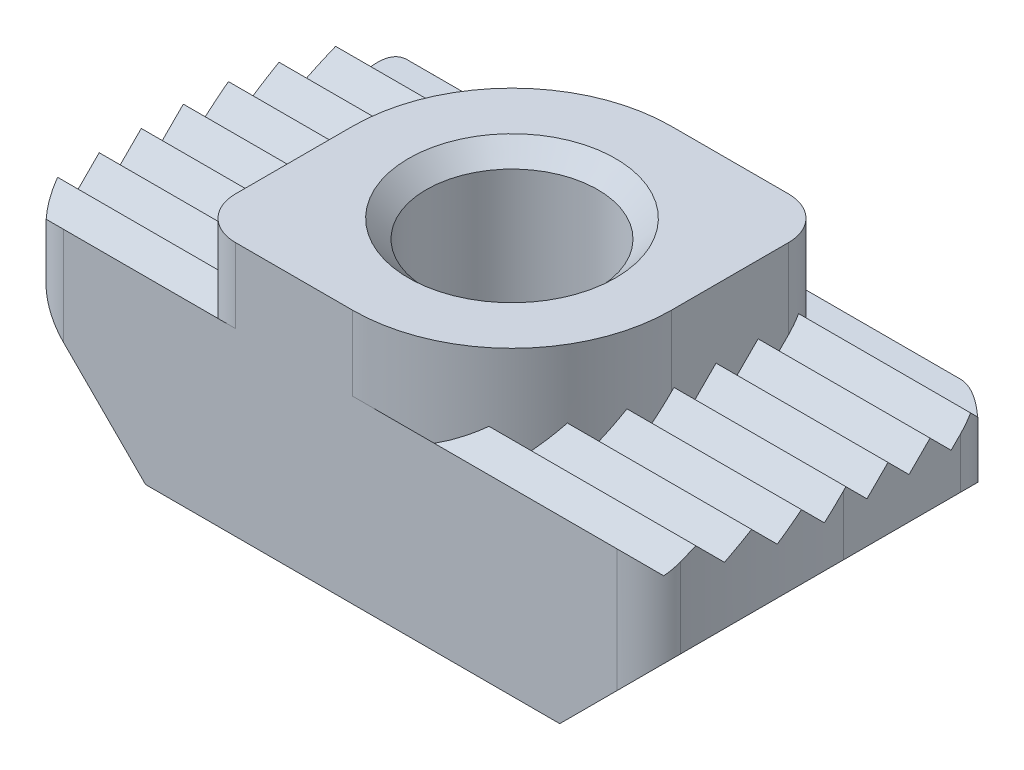
from build123d import *

# Parameters (mm, degrees)
BOSS_EXTRUDE1_DEPTH = 8.001
CUT_EXTRUDE1_DEPTH  = 7.6962
CUT_EXTRUDE2_DEPTH  = 7.6962
SKETCH8_W           = 32.004
SKETCH8_H           = 15.3924
CUT_EXTRUDE3_DEPTH  = 7.6962
BOSS_EXTRUDE2_DEPTH = 3.0734


with BuildPart() as part:
    # Sketch1 → Boss-Extrude1 (new body, symmetric)
    with BuildSketch(Plane(origin=(0, 0, 0), x_dir=(0, 0, -1), z_dir=(1, 0, 0))):
        Polygon((-3.8481, 4.34848), (-3.8481, 0), (3.8481, 0), (3.8481, 4.34848), (3.6195, 3.99288), (3.1115, 4.50088), (2.6035, 3.99288), (2.0955, 4.50088), (1.5875, 3.99288), (1.0795, 4.50088), (0.5715, 3.99288), (0.0635, 4.50088), (-0.4445, 3.99288), (-0.9525, 4.50088), (-1.4605, 3.99288), (-1.9685, 4.50088), (-2.4765, 3.99288), (-2.9845, 4.50088), (-3.4925, 3.99288), align=None)
    extrude(amount=BOSS_EXTRUDE1_DEPTH, both=True)

    # Sketch2 → Cut-Extrude1 (cut, symmetric)
    with BuildSketch(Plane.XY):
        Polygon((-10.541, 2.99974), (-10.541, -2.99974), (0, -2.99974), (0, 0), (-5.00126, 0), (-8.001, 2.99974), align=None)
    extrude(amount=CUT_EXTRUDE1_DEPTH, both=True, mode=Mode.SUBTRACT)

    # Sketch5 → Cut-Extrude2 (cut, symmetric)
    with BuildSketch(Plane.XY):
        Polygon((0, 0), (0, -2.99974), (10.541, -2.99974), (10.541, 2.99974), (8.001, 2.99974), (5.00126, 0), align=None)
    extrude(amount=CUT_EXTRUDE2_DEPTH, both=True, mode=Mode.SUBTRACT)

    # Sketch8 → Cut-Extrude3 (cut)
    with BuildSketch(Plane(origin=(0, 0, 0), x_dir=(1, 0, 0), z_dir=(0, 1, 0))):
        Rectangle(SKETCH8_W, SKETCH8_H)
        with BuildLine():
            Line((-6.985, -3.8481), (6.385094721, -3.8481))
            ThreePointArc((6.385094721, -3.8481), (6.939045596, -3.683800903), (7.313835784, -3.244041788))
            ThreePointArc((7.313835784, -3.244041788), (7.827323972, -1.658010991), (8.001, 0))
            Line((8.001, 0), (8.001, 2.8321))
            ThreePointArc((8.001, 2.8321), (7.70342049, 3.55052049), (6.985, 3.8481))
            Line((6.985, 3.8481), (-6.385094721, 3.8481))
            ThreePointArc((-6.385094721, 3.8481), (-6.939045596, 3.683800903), (-7.313835784, 3.244041788))
            ThreePointArc((-7.313835784, 3.244041788), (-7.827323972, 1.658010991), (-8.001, 0))
            Line((-8.001, 0), (-8.001, -2.8321))
            ThreePointArc((-8.001, -2.8321), (-7.70342049, -3.55052049), (-6.985, -3.8481))
        make_face(mode=Mode.SUBTRACT)
    extrude(amount=CUT_EXTRUDE3_DEPTH, mode=Mode.SUBTRACT)

    # Sketch9 → Boss-Extrude2 (add)
    with BuildSketch(Plane(origin=(0, 6.1468, 0), x_dir=(1, 0, 0), z_dir=(0, 1, 0))):
        with BuildLine():
            Line((-2.8321, -3.8481), (0, -3.8481))
            ThreePointArc((0, -3.8481), (2.721017605, -2.721017605), (3.8481, 0))
            Line((3.8481, 0), (3.8481, 2.8321))
            ThreePointArc((3.8481, 2.8321), (3.55052049, 3.55052049), (2.8321, 3.8481))
            Line((2.8321, 3.8481), (0, 3.8481))
            ThreePointArc((0, 3.8481), (-2.721017605, 2.721017605), (-3.8481, 0))
            Line((-3.8481, 0), (-3.8481, -2.8321))
            ThreePointArc((-3.8481, -2.8321), (-3.55052049, -3.55052049), (-2.8321, -3.8481))
        make_face()
    extrude(amount=-BOSS_EXTRUDE2_DEPTH)

    # Sketch10 → Cut-Revolve1 (revolve, cut)
    with BuildSketch(Plane(origin=(0, 6.1468, 0), x_dir=(-1, 0, 0), z_dir=(0, 0, 1))):
        Polygon((2.50000008, 6.1468), (0, 6.1468), (0, 0), (2.50000008, 0), (2.06699993, 0.433000023), (2.06699993, 5.713799977), align=None)
    revolve(axis=Axis((0, 6.45414, 0), (0, -1, 0)), mode=Mode.SUBTRACT)


solid = part.part
